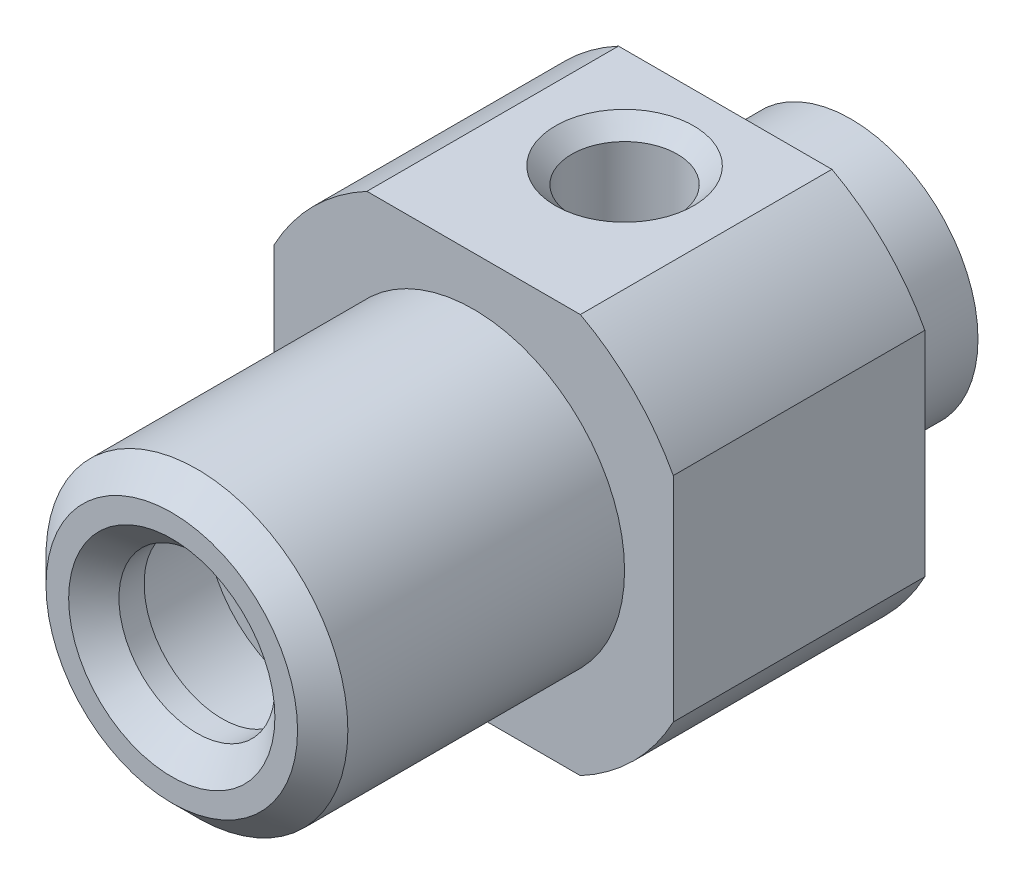
from build123d import *

# Parameters (mm, degrees)
CUT_EXTRUDE2_REACH              = 24
M5X0_8_TAPPED_HOLE1_D           = 4.2
M5X0_8_TAPPED_HOLE1_DEPTH       = 7
M5X0_8_TAPPED_HOLE1_CSINK_D     = 5.5
M5X0_8_TAPPED_HOLE1_CSINK_ANGLE = 90


with BuildPart() as part:
    # Sketch1 → Revolve1 (revolve)
    with BuildSketch(Plane(origin=(0, 0, 0), x_dir=(0, 0, -1), z_dir=(1, 0, 0))):
        Polygon((-12.5, 3.1), (-13.5, 4.1), (-13.5, 5), (-12.5, 6), (-1.5, 6), (-1.5, 9), (8.5, 9), (8.5, 5.75), (9.85, 5.75), (9.85, 5.05), (13.5, 5.05), (13.5, 2.25), (-8, 2.25), (-8, 4.15), (-11.5, 4.15), (-11.5, 3.1), align=None)
    revolve(axis=Axis((0, 0, 0), (0, 0, -1)))

    # Sketch2 → Cut-Extrude2 (cut, up to next)
    with BuildSketch(Plane(origin=(0, 0, -8.5), x_dir=(-1, 0, 0), z_dir=(0, 0, -1)), mode=Mode.PRIVATE) as cut_extrude2_sk1:
        with BuildLine():
            ThreePointArc((4.242180306, 7.9375), (0, 9), (-4.242180306, 7.9375))
            Line((-4.242180306, 7.9375), (4.242180306, 7.9375))
        make_face()
    cut_extrude2_tool1 = extrude(cut_extrude2_sk1.sketch, amount=-CUT_EXTRUDE2_REACH, mode=Mode.PRIVATE) & part.part
    add(cut_extrude2_tool1.solids().sort_by_distance((0, 8.364726, -8.5))[0], mode=Mode.SUBTRACT)
    # Sketch2 → Cut-Extrude2 (cut, up to next)
    with BuildSketch(Plane(origin=(0, 0, -8.5), x_dir=(-1, 0, 0), z_dir=(0, 0, -1)), mode=Mode.PRIVATE) as cut_extrude2_sk2:
        with BuildLine():
            Line((-7.9375, -4.242180306), (-7.9375, 4.242180306))
            ThreePointArc((-7.9375, 4.242180306), (-9, 0), (-7.9375, -4.242180306))
        make_face()
    cut_extrude2_tool2 = extrude(cut_extrude2_sk2.sketch, amount=-CUT_EXTRUDE2_REACH, mode=Mode.PRIVATE) & part.part
    add(cut_extrude2_tool2.solids().sort_by_distance((8.364726, 0, -8.5))[0], mode=Mode.SUBTRACT)
    # Sketch2 → Cut-Extrude2 (cut, up to next)
    with BuildSketch(Plane(origin=(0, 0, -8.5), x_dir=(-1, 0, 0), z_dir=(0, 0, -1)), mode=Mode.PRIVATE) as cut_extrude2_sk3:
        with BuildLine():
            Line((4.242180306, -7.9375), (-4.242180306, -7.9375))
            ThreePointArc((-4.242180306, -7.9375), (0, -9), (4.242180306, -7.9375))
        make_face()
    cut_extrude2_tool3 = extrude(cut_extrude2_sk3.sketch, amount=-CUT_EXTRUDE2_REACH, mode=Mode.PRIVATE) & part.part
    add(cut_extrude2_tool3.solids().sort_by_distance((0, -8.364726, -8.5))[0], mode=Mode.SUBTRACT)
    # Sketch2 → Cut-Extrude2 (cut, up to next)
    with BuildSketch(Plane(origin=(0, 0, -8.5), x_dir=(-1, 0, 0), z_dir=(0, 0, -1)), mode=Mode.PRIVATE) as cut_extrude2_sk4:
        with BuildLine():
            ThreePointArc((9, 0), (8.730335045, 2.186606961), (7.9375, 4.242180306))
            Line((7.9375, 4.242180306), (7.9375, -4.242180306))
            ThreePointArc((7.9375, -4.242180306), (8.730335045, -2.186606961), (9, 0))
        make_face()
    cut_extrude2_tool4 = extrude(cut_extrude2_sk4.sketch, amount=-CUT_EXTRUDE2_REACH, mode=Mode.PRIVATE) & part.part
    add(cut_extrude2_tool4.solids().sort_by_distance((-8.364726, 0, -8.5))[0], mode=Mode.SUBTRACT)

    # M5x0.8 Tapped Hole1
    with Locations(Plane(origin=(0, 7.9375, 0), x_dir=(1, 0, 0), z_dir=(0, 1, 0))):
        with Locations((0, 4.5)):
            CounterSinkHole(M5X0_8_TAPPED_HOLE1_D / 2, M5X0_8_TAPPED_HOLE1_CSINK_D / 2, depth=M5X0_8_TAPPED_HOLE1_DEPTH, counter_sink_angle=M5X0_8_TAPPED_HOLE1_CSINK_ANGLE)


solid = part.part
